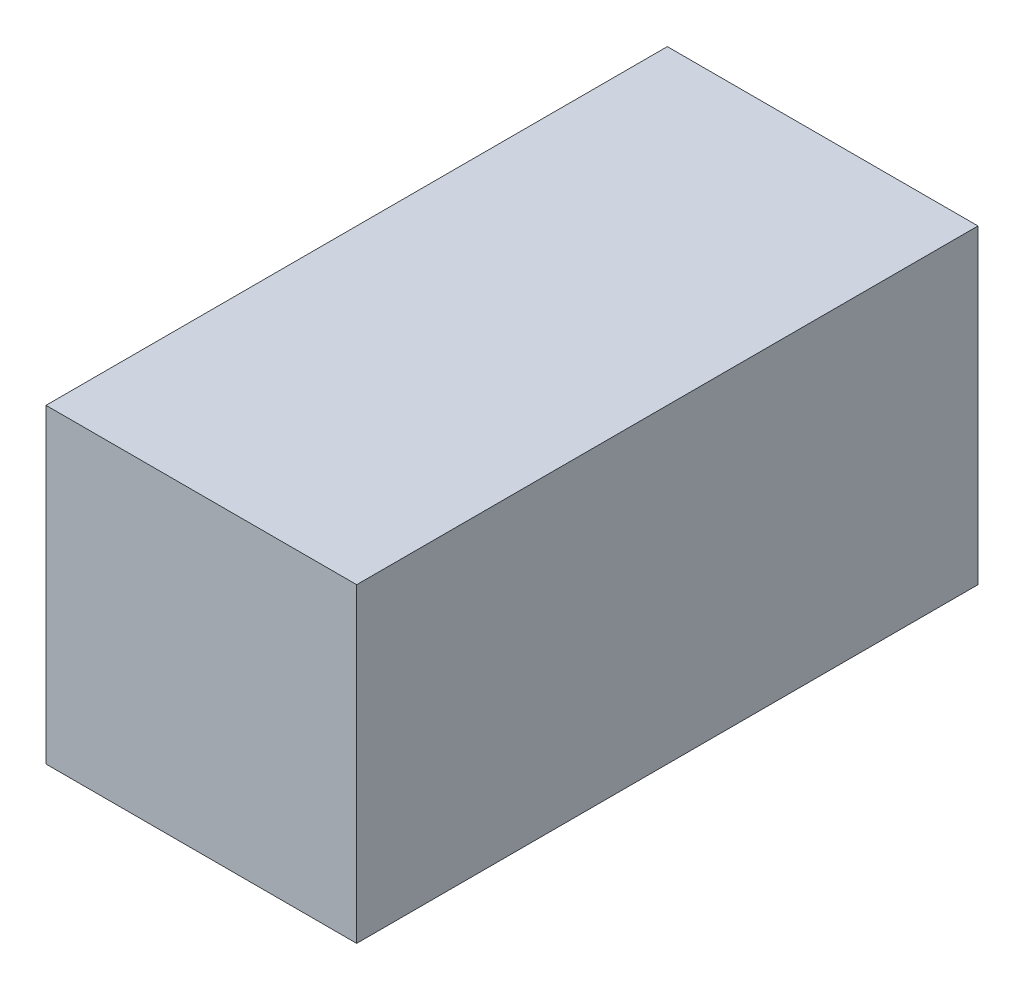
from build123d import *

# Parameters (mm, degrees)
ESQUISSE1_W        = 10
ESQUISSE1_H        = 10
BOSS_EXTRU_1_DEPTH = 20


with BuildPart() as part:
    # Esquisse1 → Boss.-Extru.1 (new body)
    with BuildSketch(Plane.XY):
        with Locations((-5, 5)):
            Rectangle(ESQUISSE1_W, ESQUISSE1_H)
    extrude(amount=BOSS_EXTRU_1_DEPTH)


solid = part.part
